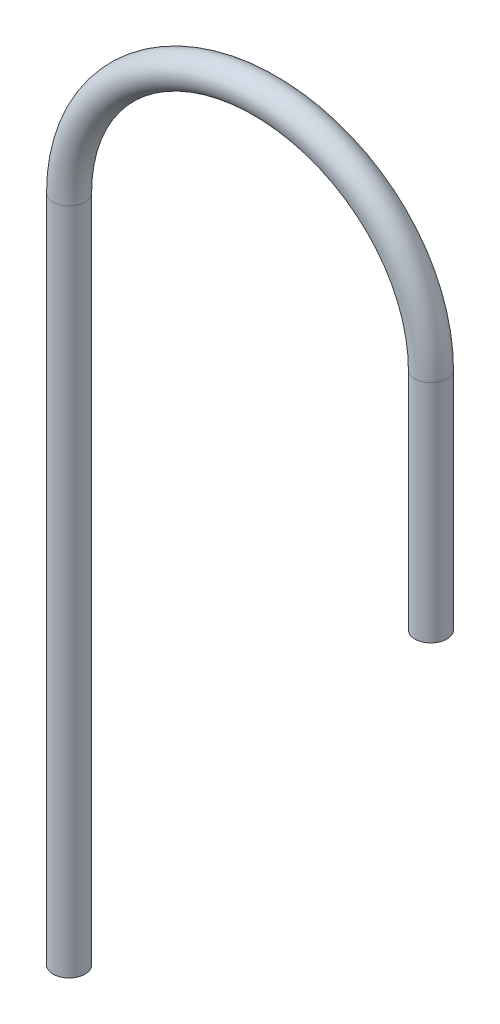
from build123d import *

# Parameters (mm, degrees)
BALAYAGE_MINCE1_PROFILE_R   = 3
BALAYAGE_MINCE1_PROFILE_R_2 = 2


with BuildPart() as part:
    # Balayage-Mince1: sweep along a curve in space
    with BuildLine() as balayage_mince1_path:
        Line((-14, 165, -59.25), (-14, 207.375, -59.25))
        ThreePointArc((-14, 207.375, -59.25), (-45.407462351, 238.890799577, -56.639074556), (-76.814924701, 207.375, -54.028149113))
        Line((-76.814924701, 207.375, -54.028149113), (-76.814924701, 81.65, -54.028149113))
    # Balayage-Mince1 profile (on start of the path) → Balayage-Mince1 (sweep)
    with BuildSketch(Plane(origin=(-14, 165, -59.25), x_dir=(0, 0, 1), z_dir=(0, 1, 0))):
        Circle(BALAYAGE_MINCE1_PROFILE_R)
        Circle(BALAYAGE_MINCE1_PROFILE_R_2, mode=Mode.SUBTRACT)
    sweep(path=balayage_mince1_path.line)


solid = part.part
